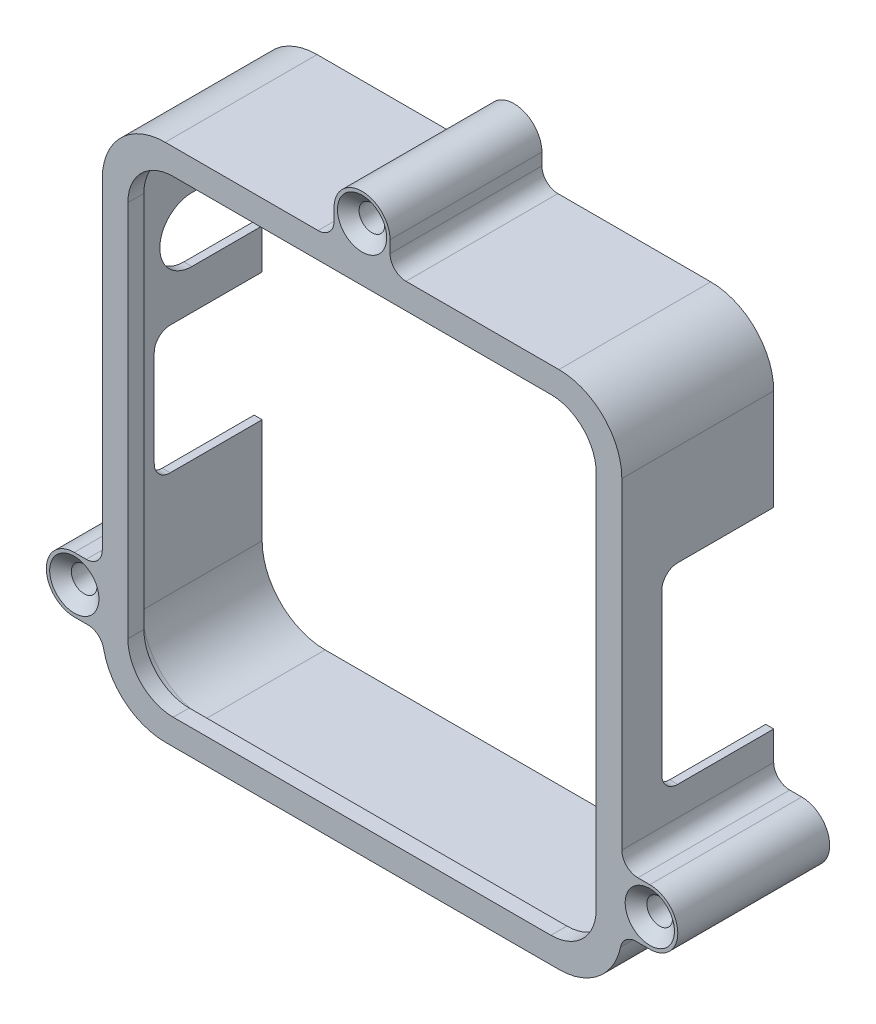
from build123d import *

# Parameters (mm, degrees)
SKETCH1_W                                          = 103.175
SKETCH1_H                                          = 103.175
SKETCH1_W_2                                        = 100
SKETCH1_H_2                                        = 100
BOSS_EXTRUDE1_DEPTH                                = 26.9875
FILLET1_R                                          = 12.5
FILLET2_R                                          = 12.5
BOSS_EXTRUDE2_DEPTH                                = 3.175
CUT_EXTRUDE1_REACH                                 = 105.175
CUT_EXTRUDE2_REACH                                 = 105.175
CUT_EXTRUDE3_REACH                                 = 105.175
FILLET5_R                                          = 3.175
BOSS_EXTRUDE3_DEPTH                                = 30.1625
CSK_FOR_10_FLAT_HEAD_MACHINE_SCREW_100_D           = 5.1054
CSK_FOR_10_FLAT_HEAD_MACHINE_SCREW_100_DEPTH       = 30.1625
CSK_FOR_10_FLAT_HEAD_MACHINE_SCREW_100_CSINK_D     = 9.779
CSK_FOR_10_FLAT_HEAD_MACHINE_SCREW_100_CSINK_ANGLE = 100
FILLET4_R                                          = 3.175


with BuildPart() as part:
    # Sketch1 → Boss-Extrude1 (new body)
    with BuildSketch(Plane.XY):
        Rectangle(SKETCH1_W, SKETCH1_H)
        Rectangle(SKETCH1_W_2, SKETCH1_H_2, mode=Mode.SUBTRACT)
    extrude(amount=BOSS_EXTRUDE1_DEPTH)

    # Fillet1
    fillet1_edges = [part.edges().sort_by_distance(p)[0] for p in [
        (50, -50, 13.49375),
        (50, 50, 13.49375),
        (-50, 50, 13.49375),
        (-50, -50, 13.49375),
    ]]
    fillet(fillet1_edges, radius=FILLET1_R)

    # Fillet2
    fillet2_edges = [part.edges().sort_by_distance(p)[0] for p in [
        (51.5875, -51.5875, 13.49375),
        (-51.5875, -51.5875, 13.49375),
        (-51.5875, 51.5875, 13.49375),
        (51.5875, 51.5875, 13.49375),
    ]]
    fillet(fillet2_edges, radius=FILLET2_R)

    # Sketch2 → Boss-Extrude2 (add)
    with BuildSketch(Plane.XY.offset(26.9875)):
        with BuildLine():
            Line((-39.0875, -51.5875), (39.0875, -51.5875))
            ThreePointArc((39.0875, -51.5875), (47.926334765, -47.926334765), (51.5875, -39.0875))
            Line((51.5875, -39.0875), (51.5875, 39.0875))
            ThreePointArc((51.5875, 39.0875), (47.926334765, 47.926334765), (39.0875, 51.5875))
            Line((39.0875, 51.5875), (-39.0875, 51.5875))
            ThreePointArc((-39.0875, 51.5875), (-47.926334765, 47.926334765), (-51.5875, 39.0875))
            Line((-51.5875, 39.0875), (-51.5875, -39.0875))
            ThreePointArc((-51.5875, -39.0875), (-47.926334765, -47.926334765), (-39.0875, -51.5875))
        make_face()
        with BuildLine():
            Line((46.5, -37.5), (46.5, 37.5))
            ThreePointArc((46.5, 37.5), (43.863961031, 43.863961031), (37.5, 46.5))
            Line((37.5, 46.5), (-37.5, 46.5))
            ThreePointArc((-37.5, 46.5), (-43.863961031, 43.863961031), (-46.5, 37.5))
            Line((-46.5, 37.5), (-46.5, -37.5))
            ThreePointArc((-46.5, -37.5), (-43.863961031, -43.863961031), (-37.5, -46.5))
            Line((-37.5, -46.5), (37.5, -46.5))
            ThreePointArc((37.5, -46.5), (43.863961031, -43.863961031), (46.5, -37.5))
        make_face(mode=Mode.SUBTRACT)
    extrude(amount=BOSS_EXTRUDE2_DEPTH)

    # Sketch3 → Cut-Extrude1 (cut, up to next)
    with BuildSketch(Plane.ZY.offset(51.5875), mode=Mode.PRIVATE) as cut_extrude1_sk1:
        with BuildLine():
            Line((0, 29.3625), (13.97, 29.3625))
            ThreePointArc((13.97, 29.3625), (20.32, 23.0125), (13.97, 16.6625))
            Line((13.97, 16.6625), (0, 16.6625))
            ThreePointArc((0, 16.6625), (-6.35, 23.0125), (0, 29.3625))
        make_face()
    cut_extrude1_tool1 = extrude(cut_extrude1_sk1.sketch, amount=-CUT_EXTRUDE1_REACH, mode=Mode.PRIVATE) & part.part
    add(cut_extrude1_tool1.solids().sort_by_distance((-51.5875, 23.0125, 6.985))[0], mode=Mode.SUBTRACT)

    # Sketch5 → Cut-Extrude2 (cut, up to next)
    with BuildSketch(Plane.ZY.offset(51.5875), mode=Mode.PRIVATE) as cut_extrude2_sk1:
        Polygon((8.73125, -16.6625), (21.43125, -16.6625), (21.43125, 8.7375), (8.73125, 8.7375), (0, 8.7375), (0, -16.6625), align=None)
    cut_extrude2_tool1 = extrude(cut_extrude2_sk1.sketch, amount=-CUT_EXTRUDE2_REACH, mode=Mode.PRIVATE) & part.part
    add(cut_extrude2_tool1.solids().sort_by_distance((-51.5875, -3.9625, 10.715625))[0], mode=Mode.SUBTRACT)

    # Sketch6 → Cut-Extrude3 (cut, up to next)
    with BuildSketch(Plane(origin=(51.5875, 0, 0), x_dir=(0, 0, -1), z_dir=(1, 0, 0)), mode=Mode.PRIVATE) as cut_extrude3_sk1:
        Polygon((-3.175, -19.05), (-22.225, -19.05), (-22.225, 19.05), (-3.175, 19.05), (0, 19.05), (0, -19.05), align=None)
    cut_extrude3_tool1 = extrude(cut_extrude3_sk1.sketch, amount=-CUT_EXTRUDE3_REACH, mode=Mode.PRIVATE) & part.part
    add(cut_extrude3_tool1.solids().sort_by_distance((51.5875, 0, 11.1125))[0], mode=Mode.SUBTRACT)

    # Fillet5
    fillet5_edges = [part.edges().sort_by_distance(p)[0] for p in [
        (-50.79375, -16.6625, 21.43125),
        (-50.79375, 8.7375, 21.43125),
        (50.79375, 19.05, 22.225),
        (50.79375, -19.05, 22.225),
        (50, 0, 26.9875),
        (0, 50, 26.9875),
        (0, -50, 26.9875),
        (-50, 0, 26.9875),
        (46.338834765, 46.338834765, 26.9875),
        (46.338834765, -46.338834765, 26.9875),
        (-46.338834765, -46.338834765, 26.9875),
        (-46.338834765, 46.338834765, 26.9875),
    ]]
    fillet(fillet5_edges, radius=FILLET5_R)

    # Sketch7 → Boss-Extrude3 (add)
    with BuildSketch(Plane.XY.offset(30.1625)):
        with BuildLine():
            Line((57.14375, -27.975), (51.5875, -27.975))
            Line((51.5875, -27.975), (51.5875, -39.0875))
            Line((51.5875, -39.0875), (57.14375, -39.0875))
            ThreePointArc((57.14375, -39.0875), (62.7, -33.53125), (57.14375, -27.975))
        make_face()
        with BuildLine():
            Line((-51.5875, -39.0875), (-57.14375, -39.0875))
            ThreePointArc((-57.14375, -39.0875), (-62.7, -33.53125), (-57.14375, -27.975))
            Line((-57.14375, -27.975), (-51.5875, -27.975))
            Line((-51.5875, -27.975), (-51.5875, -39.0875))
        make_face()
        with BuildLine():
            Line((-5.55625, 51.5875), (5.55625, 51.5875))
            Line((5.55625, 51.5875), (5.55625, 57.14375))
            ThreePointArc((5.55625, 57.14375), (0, 62.7), (-5.55625, 57.14375))
            Line((-5.55625, 57.14375), (-5.55625, 51.5875))
        make_face()
    extrude(amount=-BOSS_EXTRUDE3_DEPTH)

    # CSK for #10 Flat Head Machine Screw (100)1
    with Locations(Plane(origin=(57.14375, -33.53125, 30.1625), x_dir=(1, 0, 0), z_dir=(0, 0, 1))):
        with Locations((0, 0), (-114.2875, 0), (-57.14375, 90.675)):
            CounterSinkHole(CSK_FOR_10_FLAT_HEAD_MACHINE_SCREW_100_D / 2, CSK_FOR_10_FLAT_HEAD_MACHINE_SCREW_100_CSINK_D / 2, depth=CSK_FOR_10_FLAT_HEAD_MACHINE_SCREW_100_DEPTH, counter_sink_angle=CSK_FOR_10_FLAT_HEAD_MACHINE_SCREW_100_CSINK_ANGLE)

    # Fillet4
    fillet4_edges = [part.edges().sort_by_distance(p)[0] for p in [
        (51.5875, -27.975, 15.08125),
        (-51.5875, -27.975, 15.08125),
        (5.55625, 51.5875, 15.08125),
        (-5.55625, 51.5875, 15.08125),
        (51.5875, -39.0875, 15.08125),
        (-51.5875, -39.0875, 15.08125),
    ]]
    fillet(fillet4_edges, radius=FILLET4_R)


solid = part.part
